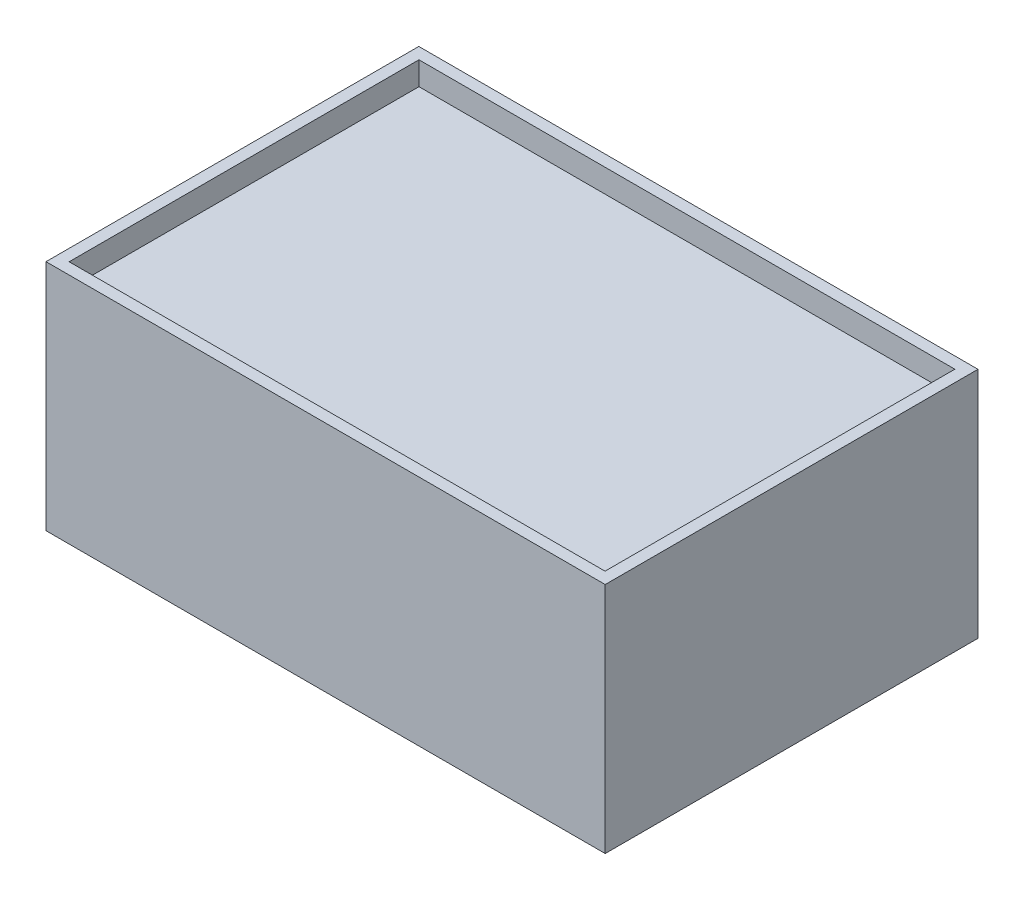
from build123d import *

# Parameters (mm, degrees)
SKETCH1_W           = 152.4
SKETCH1_H           = 63.5
BOSS_EXTRUDE1_DEPTH = 101.6
SKETCH3_W           = 146.05
SKETCH3_H           = 95.34
CUT_EXTRUDE1_DEPTH  = 6.35


with BuildPart() as part:
    # Sketch1 → Boss-Extrude1 (new body)
    with BuildSketch(Plane.XY):
        Rectangle(SKETCH1_W, SKETCH1_H)
    extrude(amount=-BOSS_EXTRUDE1_DEPTH)

    # Sketch3 → Cut-Extrude1 (cut)
    with BuildSketch(Plane(origin=(0, 31.75, 0), x_dir=(1, 0, 0), z_dir=(0, 1, 0))):
        with Locations((0, 50.8)):
            Rectangle(SKETCH3_W, SKETCH3_H)
    cut_extrude1 = extrude(amount=-CUT_EXTRUDE1_DEPTH, mode=Mode.SUBTRACT)

    # Mirror1: Cut-Extrude1 across plane
    add(cut_extrude1.mirror(Plane.ZX), mode=Mode.SUBTRACT)


solid = part.part
